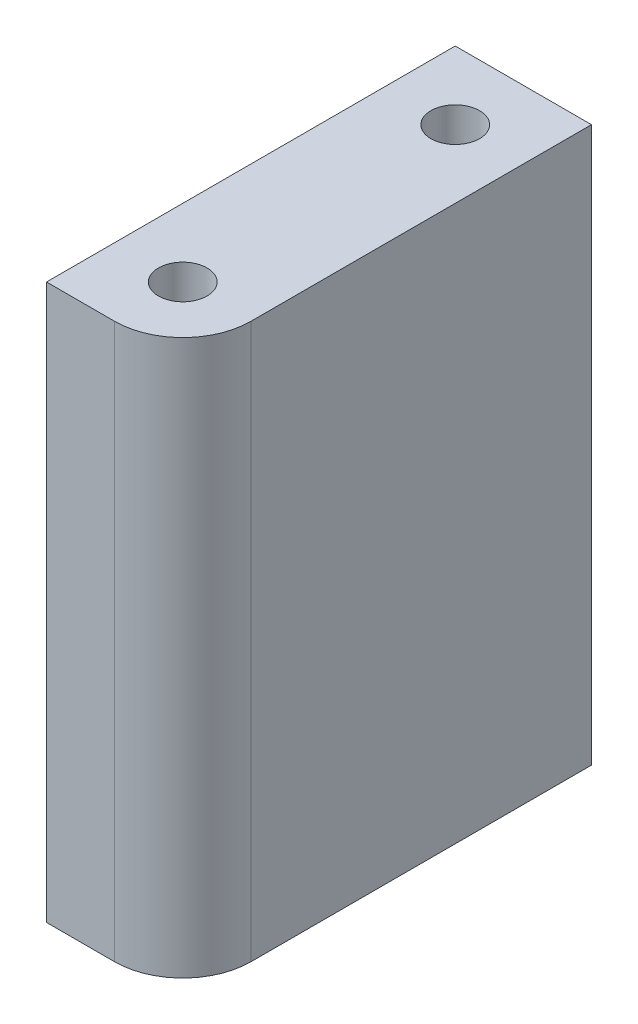
from build123d import *

# Parameters (mm, degrees)
SKETCH_1_R      = 2.5
EXTRUDE_1_DEPTH = 57


with BuildPart() as part:
    # 草图1 → 凸台-拉伸1 (new body)
    with BuildSketch(Plane(origin=(0, 0, 0), x_dir=(1, 0, 0), z_dir=(0, 1, 0))):
        with BuildLine():
            Line((-7, 21), (7, 21))
            Line((7, 21), (7, -14))
            ThreePointArc((7, -14), (4.949747468, -18.949747468), (0, -21))
            Line((0, -21), (-7, -21))
            Line((-7, -21), (-7, 21))
        make_face()
        with Locations((0, 14)):
            Circle(SKETCH_1_R, mode=Mode.SUBTRACT)
        with Locations((0, -14)):
            Circle(SKETCH_1_R, mode=Mode.SUBTRACT)
    extrude(amount=EXTRUDE_1_DEPTH)


solid = part.part
